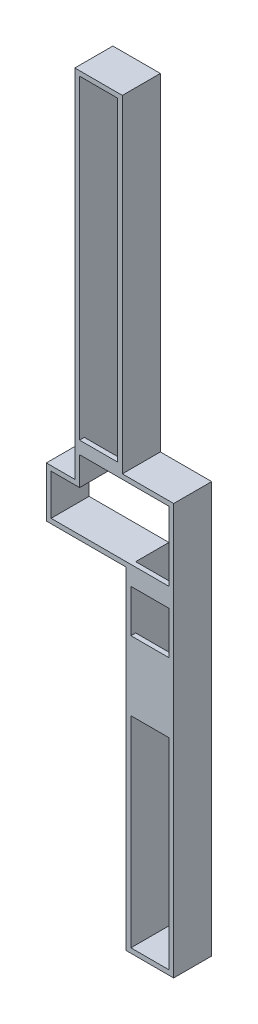
from build123d import *

# Parameters (mm, degrees)
SALIENTE_EXTRUIR1_DEPTH = 800
CROQUIS2_W              = 800
CROQUIS2_H              = 400
SALIENTE_EXTRUIR2_DEPTH = 100
CROQUIS3_W              = 800
CROQUIS3_H              = 1458.339782358
SALIENTE_EXTRUIR3_DEPTH = 100
CROQUIS4_W              = 800
CROQUIS4_H              = 265
SALIENTE_EXTRUIR4_DEPTH = 100


with BuildPart() as part:
    # Croquis1 → Saliente-Extruir1 (new body)
    with BuildSketch(Plane.XY):
        Polygon((1606.453179542, -7950), (1706.453179542, -7950), (1706.453179542, 99.648210299), (1706.453179542, 499.648210299), (1706.453179542, 599.648210299), (1706.453179542, 700), (626.453179542, 700), (626.453179542, 7600), (-373.546820458, 7600), (-373.546820458, 100), (-973.546820458, 100), (-973.546820458, -960), (706.453179542, -960), (706.453179542, -7950), align=None)
        Polygon((-273.546820458, 0), (-273.546820458, 7500), (526.453179542, 7500), (526.453179542, 600), (1606.453179542, 600), (1606.453179542, 499.648210299), (1606.453179542, 399.648210299), (1606.453179542, 0), (1606.453179542, -2193.685123034), (1606.453179542, -7850), (806.453179542, -7850), (806.453179542, -860), (-373.546820458, -860), (-873.546820458, -860), (-873.546820458, 0), align=None, mode=Mode.SUBTRACT)
    extrude(amount=SALIENTE_EXTRUIR1_DEPTH)

    # Croquis2 → Saliente-Extruir2 (add)
    with BuildSketch(Plane.XY.offset(800)):
        with Locations((1206.453179542, -1060)):
            Rectangle(CROQUIS2_W, CROQUIS2_H)
    extrude(amount=-SALIENTE_EXTRUIR2_DEPTH)

    # Croquis3 → Saliente-Extruir3 (add)
    with BuildSketch(Plane.XY.offset(800)):
        with Locations((1206.453179542, -2889.169891179)):
            Rectangle(CROQUIS3_W, CROQUIS3_H)
    extrude(amount=-SALIENTE_EXTRUIR3_DEPTH)

    # Croquis4 → Saliente-Extruir4 (add)
    with BuildSketch(Plane.XY.offset(800)):
        with Locations((126.453179542, 732.5)):
            Rectangle(CROQUIS4_W, CROQUIS4_H)
    extrude(amount=-SALIENTE_EXTRUIR4_DEPTH)


solid = part.part
